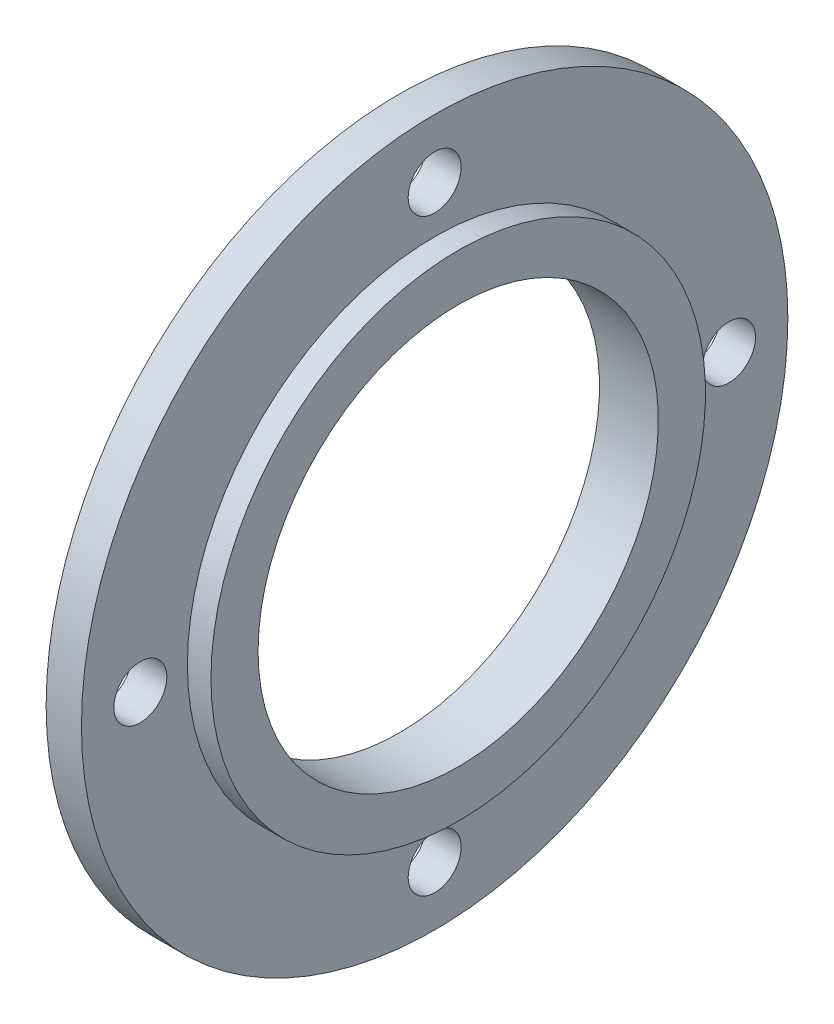
from build123d import *

# Parameters (mm, degrees)
M4_CLEARANCE_HOLE1_D     = 4.5
M4_CLEARANCE_HOLE1_DEPTH = 3.001
CIRPATTERN1_COUNT        = 4


with BuildPart() as part:
    # Sketch1 → Revolve1 (revolve)
    with BuildSketch(Plane.XY):
        Polygon((0, 17), (5, 17), (5, 21), (3, 21), (3, 30), (0, 30), align=None)
    revolve(axis=Axis((0, 0, 0), (1, 0, 0)))

    # M4 Clearance Hole1
    with Locations(Plane.ZY):
        with Locations((0, 25)):
            m4_clearance_hole1 = Hole(M4_CLEARANCE_HOLE1_D / 2, depth=M4_CLEARANCE_HOLE1_DEPTH)

    # CirPattern1: M4 Clearance Hole1 ×4 about axis
    cirpattern1_axis = Axis((0, 0, 0), (1, 0, 0))
    for i in range(1, CIRPATTERN1_COUNT):
        add(m4_clearance_hole1.rotate(cirpattern1_axis, i * 360 / CIRPATTERN1_COUNT), mode=Mode.SUBTRACT)


solid = part.part
